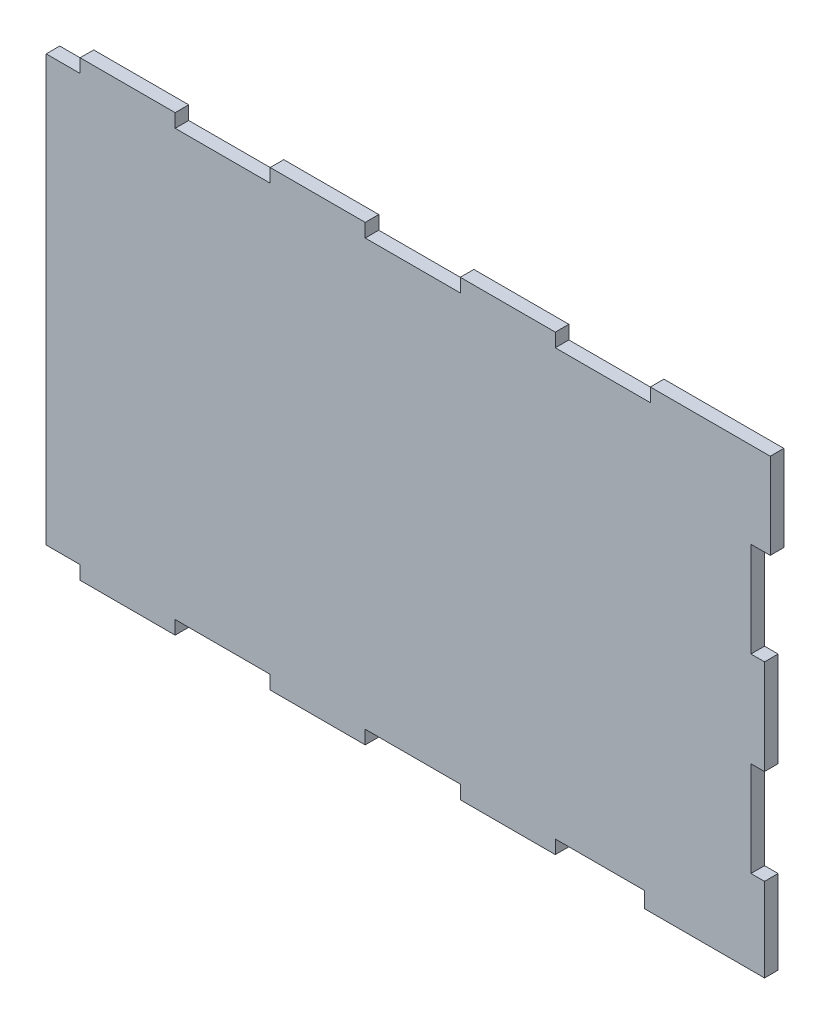
from build123d import *

# Parameters (mm, degrees)
SALIENTE_EXTRUIR1_DEPTH = 3
CORTAR_EXTRUIR3_DEPTH   = 10


with BuildPart() as part:
    # Croquis1 → Saliente-Extruir1 (new body)
    with BuildSketch(Plane.XY):
        Polygon((-99.368109251, 50.24258427), (-99.368109251, 31.74258427), (-96.368109251, 31.74258427), (-96.368109251, 10.74258427), (-99.368109251, 10.74258427), (-99.368109251, -10.25741573), (-96.368109251, -10.25741573), (-96.368109251, -31.25741573), (-99.368109251, -31.25741573), (-99.368109251, -49.75741573), (-72.868109251, -49.75741573), (-72.868109251, -46.75741573), (-51.868109251, -46.75741573), (-51.868109251, -49.75741573), (-30.868109251, -49.75741573), (-30.868109251, -46.75741573), (-9.868109251, -46.75741573), (-9.868109251, -49.75741573), (11.131890749, -49.75741573), (11.131890749, -46.75741573), (32.131890749, -46.75741573), (32.131890749, -49.75741573), (53.131890749, -49.75741573), (53.131890749, -46.75741573), (72.868109251, -46.75741573), (72.868109251, -50.24258427), (93.868109251, -50.24258427), (99.368109251, -50.24258427), (99.368109251, -31.74258427), (96.368109251, -31.74258427), (96.368109251, -10.74258427), (99.368109251, -10.74258427), (99.368109251, 10.25741573), (96.368109251, 10.25741573), (96.368109251, 31.25741573), (100.631890749, 31.25741573), (100.631890749, 50.24258427), (74.131890749, 50.24258427), (74.131890749, 47.24258427), (53.131890749, 47.24258427), (53.131890749, 50.24258427), (32.131890749, 50.24258427), (32.131890749, 47.24258427), (11.131890749, 47.24258427), (11.131890749, 50.24258427), (-9.868109251, 50.24258427), (-9.868109251, 47.24258427), (-30.868109251, 47.24258427), (-30.868109251, 50.24258427), (-51.868109251, 50.24258427), (-51.868109251, 47.24258427), (-72.868109251, 47.24258427), (-72.868109251, 50.24258427), (-93.868109251, 50.24258427), align=None)
    extrude(amount=SALIENTE_EXTRUIR1_DEPTH)

    # Croquis2 → Cortar-Extruir3 (cut)
    with BuildSketch(Plane.XY.offset(3)):
        Polygon((-72.868109251, 50.24258427), (-99.368109251, 50.24258427), (-99.368109251, 31.74258427), (-96.368109251, 31.74258427), (-96.368109251, 10.74258427), (-99.368109251, 10.74258427), (-99.368109251, -10.25741573), (-96.368109251, -10.25741573), (-96.368109251, -31.25741573), (-99.368109251, -31.25741573), (-99.368109251, -49.75741573), (-72.868109251, -49.75741573), (-72.868109251, -46.75741573), (-59.368109251, -46.75741573), (-59.368109251, 47.24258427), (-72.868109251, 47.24258427), align=None)
    extrude(amount=-CORTAR_EXTRUIR3_DEPTH, mode=Mode.SUBTRACT)


solid = part.part
